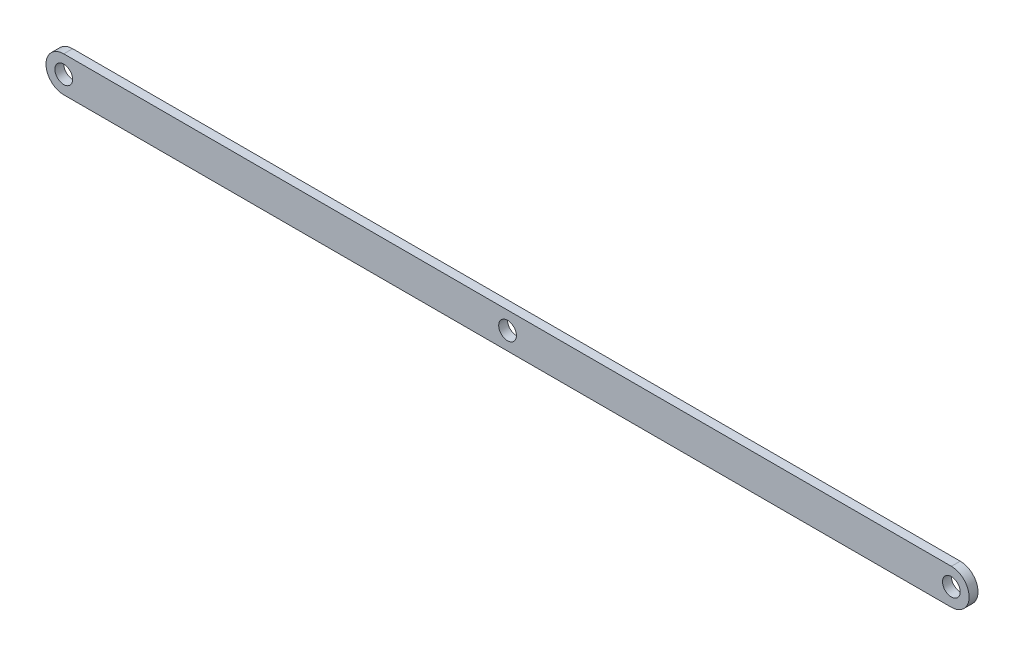
from build123d import *

# Parameters (mm, degrees)
SKETCH1_R           = 5
BOSS_EXTRUDE1_DEPTH = 5


with BuildPart() as part:
    # Sketch1 → Boss-Extrude1 (new body)
    with BuildSketch(Plane.XY):
        with BuildLine():
            Line((-250, 10), (250, 10))
            ThreePointArc((250, 10), (260, 0), (250, -10))
            Line((250, -10), (-250, -10))
            ThreePointArc((-250, -10), (-260, 0), (-250, 10))
        make_face()
        with Locations((-250, 0)):
            Circle(SKETCH1_R, mode=Mode.SUBTRACT)
        with Locations((250, 0)):
            Circle(SKETCH1_R, mode=Mode.SUBTRACT)
        Circle(SKETCH1_R, mode=Mode.SUBTRACT)
    extrude(amount=BOSS_EXTRUDE1_DEPTH)


solid = part.part
